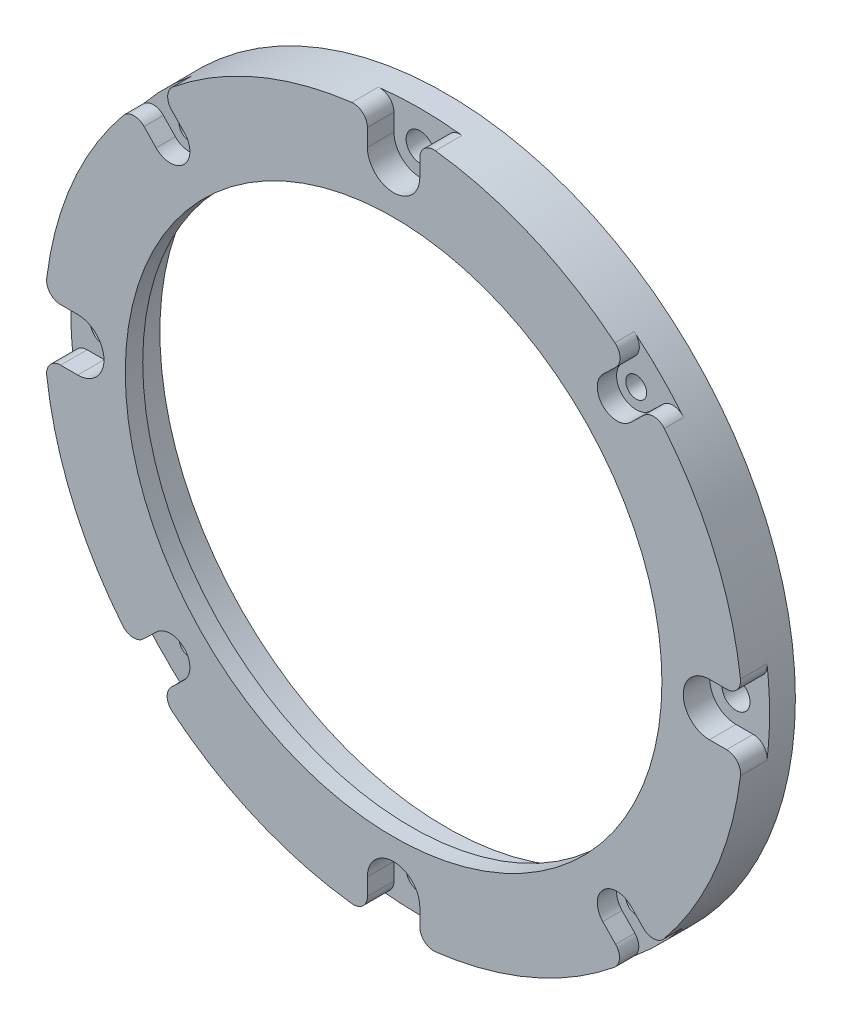
from build123d import *

# Parameters (mm, degrees)
SKETCH2_R                                       = 52
CUT_EXTRUDE1_DEPTH                              = 7.35
CBORE_FOR_6_SOCKET_HEAD_CAP_SCREW1_D            = 3.7973
CBORE_FOR_6_SOCKET_HEAD_CAP_SCREW1_CBORE_D      = 7.14502
CBORE_FOR_6_SOCKET_HEAD_CAP_SCREW1_CBORE_DEPTH  = 3.5052
CUT_EXTRUDE3_DEPTH                              = 3.5052
FILLET2_R                                       = 2.54
CIRPATTERN1_COUNT                               = 4
FILLET2_OF_CIRPATTERN1_R                        = 2.54
CBORE_FOR_10_SOCKET_HEAD_CAP_SCREW1_D           = 5.1054
CBORE_FOR_10_SOCKET_HEAD_CAP_SCREW1_CBORE_D     = 9.525
CBORE_FOR_10_SOCKET_HEAD_CAP_SCREW1_CBORE_DEPTH = 4.826
SKETCH12_W                                      = 9.525
SKETCH12_H                                      = 6.096
CUT_EXTRUDE2_DEPTH                              = 4.826
FILLET1_R                                       = 2.54
CIRPATTERN2_COUNT                               = 4
FILLET1_OF_CIRPATTERN2_R                        = 2.54


with BuildPart() as part:
    # Sketch1 → Revolve1 (revolve)
    with BuildSketch(Plane(origin=(0, 0, 0), x_dir=(1, 0, 0), z_dir=(0, 1, 0))):
        Polygon((0, 0), (63.5, 0), (63.5, -9.525), (48.768, -9.525), (48.768, -6.35), (0, -6.35), align=None)
    revolve(axis=Axis((0, 0, 6.35), (0, 0, -1)))

    # Sketch2 → Cut-Extrude1 (cut, through all)
    with BuildSketch(Plane.XY.offset(6.35)):
        Circle(SKETCH2_R)
    extrude(amount=-CUT_EXTRUDE1_DEPTH, mode=Mode.SUBTRACT)

    # CBORE for #6 Socket Head Cap Screw1 (through all)
    with Locations(Plane(origin=(41.748308106, 9.089250186, 9.525), x_dir=(-1, 0, 0), z_dir=(0, 0, 1))):
        with Locations((82.339065773, -31.501507481)):
            cbore_for_6_socket_head_cap_screw1 = CounterBoreHole(CBORE_FOR_6_SOCKET_HEAD_CAP_SCREW1_D / 2, CBORE_FOR_6_SOCKET_HEAD_CAP_SCREW1_CBORE_D / 2, CBORE_FOR_6_SOCKET_HEAD_CAP_SCREW1_CBORE_DEPTH)

    # Sketch15 → Cut-Extrude3 (cut)
    with BuildSketch(Plane.XY.offset(9.525)):
        Polygon((-43.163572896, 38.112159374), (-38.017942439, 43.069355961), (-42.254257335, 47.466702439), (-47.399887791, 42.509505852), align=None)
    cut_extrude3 = extrude(amount=-CUT_EXTRUDE3_DEPTH, mode=Mode.SUBTRACT)

    # Fillet2
    fillet2_edges = [part.edges().sort_by_distance(p)[0] for p in [
        (-42.220045282, 47.431189911, 7.7724),
        (-47.281962218, 42.38709767, 7.7724),
    ]]
    fillet(fillet2_edges, radius=FILLET2_R)

    # CirPattern1: CBORE for #6 Socket Head Cap Screw1, Cut-Extrude3 ×4 about axis
    cirpattern1_axis = Axis((0, 0, 0), (0, 0, 1))
    for i in range(1, CIRPATTERN1_COUNT):
        add(cbore_for_6_socket_head_cap_screw1.rotate(cirpattern1_axis, i * 360 / CIRPATTERN1_COUNT), mode=Mode.SUBTRACT)
        add(cut_extrude3.rotate(cirpattern1_axis, i * 360 / CIRPATTERN1_COUNT), mode=Mode.SUBTRACT)

    # Fillet2 of CirPattern1
    fillet2_of_cirpattern1_edges = [part.edges().sort_by_distance(p)[0] for p in [
        (-47.431189911, -42.220045282, 7.7724),
        (-42.38709767, -47.281962218, 7.7724),
        (42.220045282, -47.431189911, 7.7724),
        (47.281962218, -42.38709767, 7.7724),
        (47.431189911, 42.220045282, 7.7724),
        (42.38709767, 47.281962218, 7.7724),
    ]]
    fillet(fillet2_of_cirpattern1_edges, radius=FILLET2_OF_CIRPATTERN1_R)

    # CBORE for #10 Socket Head Cap Screw1 (through all)
    with Locations(Plane.XY.offset(9.525)):
        with Locations((0, 57.404)):
            cbore_for_10_socket_head_cap_screw1 = CounterBoreHole(CBORE_FOR_10_SOCKET_HEAD_CAP_SCREW1_D / 2, CBORE_FOR_10_SOCKET_HEAD_CAP_SCREW1_CBORE_D / 2, CBORE_FOR_10_SOCKET_HEAD_CAP_SCREW1_CBORE_DEPTH)

    # Sketch12 → Cut-Extrude2 (cut)
    with BuildSketch(Plane.XY.offset(9.525)):
        with Locations((0, 60.452)):
            Rectangle(SKETCH12_W, SKETCH12_H)
    cut_extrude2 = extrude(amount=-CUT_EXTRUDE2_DEPTH, mode=Mode.SUBTRACT)

    # Fillet1
    fillet1_edges = [part.edges().sort_by_distance(p)[0] for p in [
        (4.7625, 63.321154394, 7.112),
        (-4.7625, 63.321154394, 7.112),
    ]]
    fillet(fillet1_edges, radius=FILLET1_R)

    # CirPattern2: CBORE for #10 Socket Head Cap Screw1, Cut-Extrude2 ×4 about axis
    cirpattern2_axis = Axis((0, 0, 0), (0, 0, 1))
    for i in range(1, CIRPATTERN2_COUNT):
        add(cbore_for_10_socket_head_cap_screw1.rotate(cirpattern2_axis, i * 360 / CIRPATTERN2_COUNT), mode=Mode.SUBTRACT)
        add(cut_extrude2.rotate(cirpattern2_axis, i * 360 / CIRPATTERN2_COUNT), mode=Mode.SUBTRACT)

    # Fillet1 of CirPattern2
    fillet1_of_cirpattern2_edges = [part.edges().sort_by_distance(p)[0] for p in [
        (-63.321154394, 4.7625, 7.112),
        (-63.321154394, -4.7625, 7.112),
        (-4.7625, -63.321154394, 7.112),
        (4.7625, -63.321154394, 7.112),
        (63.321154394, -4.7625, 7.112),
        (63.321154394, 4.7625, 7.112),
    ]]
    fillet(fillet1_of_cirpattern2_edges, radius=FILLET1_OF_CIRPATTERN2_R)


solid = part.part
